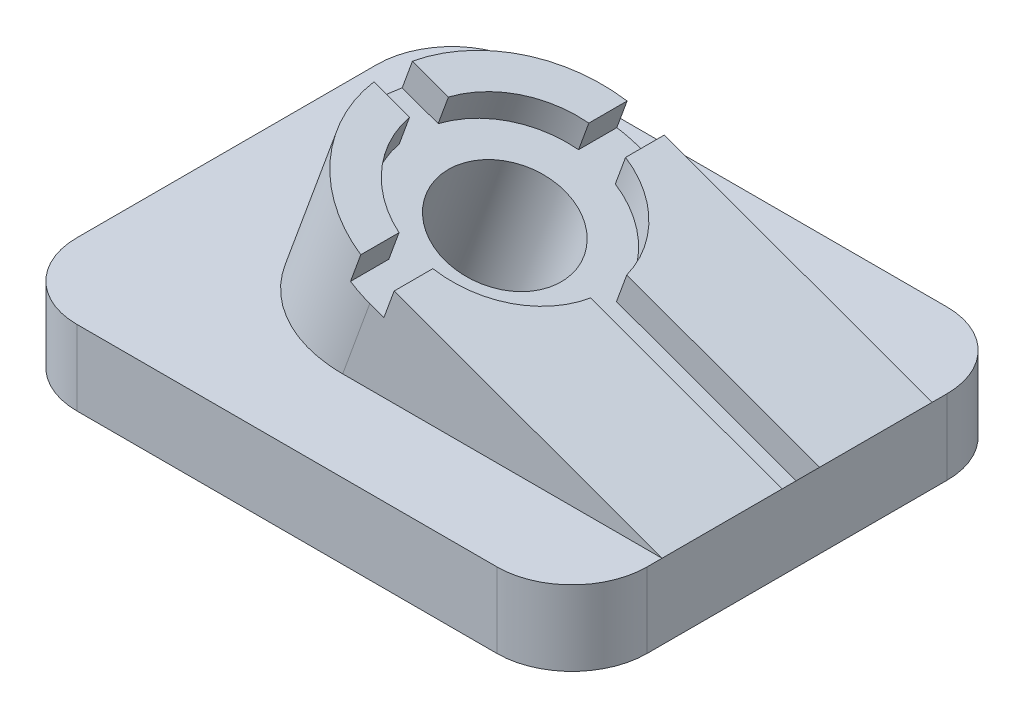
from build123d import *

# Parameters (mm, degrees)
BOSS_EXTRUDE1_DEPTH = 30
BOSS_EXTRUDE2_DEPTH = 18
CUT_EXTRUDE1_REACH  = 59.518
SKETCH12_4_R        = 8
CUT_EXTRUDE2_DEPTH  = 58.518373937
SKETCH12_5_R        = 8
CUT_EXTRUDE3_DEPTH  = 4
FILLET1_R           = 10


with BuildPart() as part:
    # Sketch1 → Boss-Extrude1 (new, symmetric)
    with BuildSketch(Plane.XY):
        Polygon((-23.722310804, 5), (-38, 5), (-38, -5), (38, -5), (38, 5), align=None)
    extrude(amount=BOSS_EXTRUDE1_DEPTH, both=True)

    # Sketch1_4 → Boss-Extrude2 (add, symmetric)
    with BuildSketch(Plane.XY):
        Polygon((-16.502172006, 24.837168313), (-23.722310804, 5), (38, 5), align=None)
    extrude(amount=BOSS_EXTRUDE2_DEPTH, both=True)

    # Cut-Extrude1: up to this plane
    cut_extrude1_end = Plane(origin=(0, 5, 30), z_dir=(0, 1, 0))
    # Sketch2 → Cut-Extrude1 (cut, up to the surface)
    with BuildSketch(Plane(origin=(6.052124605, 16.628075692, 0), x_dir=(0.9396926207859105, -0.34202014332566305, 0), z_dir=(0.34202014332566305, 0.9396926207859105, 0)), mode=Mode.PRIVATE) as cut_extrude1_sk1:
        with BuildLine():
            Line((-6.001781127, 18), (-24.001781127, 18))
            Line((-24.001781127, 18), (-24.001781127, -2e-09))
            ThreePointArc((-24.001781127, -2e-09), (-18.729703189, 12.727922061), (-6.001781127, 18))
        make_face()
    cut_extrude1_tool1 = split(extrude(cut_extrude1_sk1.sketch, amount=-CUT_EXTRUDE1_REACH, mode=Mode.PRIVATE), bisect_by=cut_extrude1_end, keep=Keep.BOTH, mode=Mode.PRIVATE)
    add(cut_extrude1_tool1.solids().sort_by_distance((-12.724022, 23.462034, -13.979377))[0], mode=Mode.SUBTRACT)
    # Sketch2 → Cut-Extrude1 (cut, up to the surface)
    with BuildSketch(Plane(origin=(6.052124605, 16.628075692, 0), x_dir=(0.9396926207859105, -0.34202014332566305, 0), z_dir=(0.34202014332566305, 0.9396926207859105, 0)), mode=Mode.PRIVATE) as cut_extrude1_sk2:
        with BuildLine():
            ThreePointArc((-6.001781127, -18), (-18.729703188, -12.727922062), (-24.001781127, -2e-09))
            Line((-24.001781127, -2e-09), (-24.001781127, -18))
            Line((-24.001781127, -18), (-6.001781127, -18))
        make_face()
    cut_extrude1_tool2 = split(extrude(cut_extrude1_sk2.sketch, amount=-CUT_EXTRUDE1_REACH, mode=Mode.PRIVATE), bisect_by=cut_extrude1_end, keep=Keep.BOTH, mode=Mode.PRIVATE)
    add(cut_extrude1_tool2.solids().sort_by_distance((-12.724022, 23.462034, 13.979377))[0], mode=Mode.SUBTRACT)

    # Sketch12_4 → Cut-Extrude2 (cut, through all)
    with BuildSketch(Plane(origin=(6.052124605, 16.628075692, 0), x_dir=(0.9396926207859105, -0.34202014332566305, 0), z_dir=(0.34202014332566305, 0.9396926207859105, 0))):
        with Locations((-6.001781127, 0)):
            Circle(SKETCH12_4_R)
    extrude(amount=-CUT_EXTRUDE2_DEPTH, mode=Mode.SUBTRACT)

    # Sketch12_5 → Cut-Extrude3 (cut)
    with BuildSketch(Plane(origin=(6.052124605, 16.628075692, 0), x_dir=(0.9396926207859105, -0.34202014332566305, 0), z_dir=(0.34202014332566305, 0.9396926207859105, 0))):
        with BuildLine():
            ThreePointArc((-23.750020476, 3), (-23.938730537, 1.505272688), (-24.001781127, 5e-09))
            ThreePointArc((-24.001781127, 5e-09), (-23.973895482, -1.001551604), (-23.890324947, -2))
            Line((-23.890324947, -2), (-18.847013705, -2))
            ThreePointArc((-18.847013705, -2), (-15.547394686, -8.825036078), (-9.001781127, -12.649110641))
            Line((-9.001781127, -12.649110641), (-9.001781127, -17.748239349))
            ThreePointArc((-9.001781127, -17.748239349), (-7.507053812, -17.93694941), (-6.001781127, -18))
            Line((-6.001781127, -18), (-4.001781127, -18))
            Line((-4.001781127, -18), (-4.001781127, -12.845232579))
            ThreePointArc((-4.001781127, -12.845232579), (3.190607029, -9.192388155), (6.843451452, -2))
            Line((6.843451452, -2), (33.998218873, -2))
            Line((33.998218873, -2), (33.998218873, 3))
            Line((33.998218873, 3), (6.647329514, 3))
            ThreePointArc((6.647329514, 3), (2.823254951, 9.54561356), (-4.001781127, 12.845232579))
            Line((-4.001781127, 12.845232579), (-4.001781127, 18))
            Line((-4.001781127, 18), (-6.001781127, 18))
            ThreePointArc((-6.001781127, 18), (-7.507053812, 17.93694941), (-9.001781127, 17.748239349))
            Line((-9.001781127, 17.748239349), (-9.001781127, 12.649110641))
            ThreePointArc((-9.001781127, 12.649110641), (-15.194169282, 9.192388155), (-18.650891767, 3))
            Line((-18.650891767, 3), (-23.750020476, 3))
        make_face()
        with Locations((-6.001781127, 0)):
            Circle(SKETCH12_5_R, mode=Mode.SUBTRACT)
    extrude(amount=-CUT_EXTRUDE3_DEPTH, mode=Mode.SUBTRACT)

    # Fillet1
    fillet1_edges = [part.edges().sort_by_distance(p)[0] for p in [
        (-38, 0, -30),
        (38, 0, -30),
        (38, 0, 30),
        (-38, 0, 30),
    ]]
    fillet(fillet1_edges, radius=FILLET1_R)


solid = part.part
